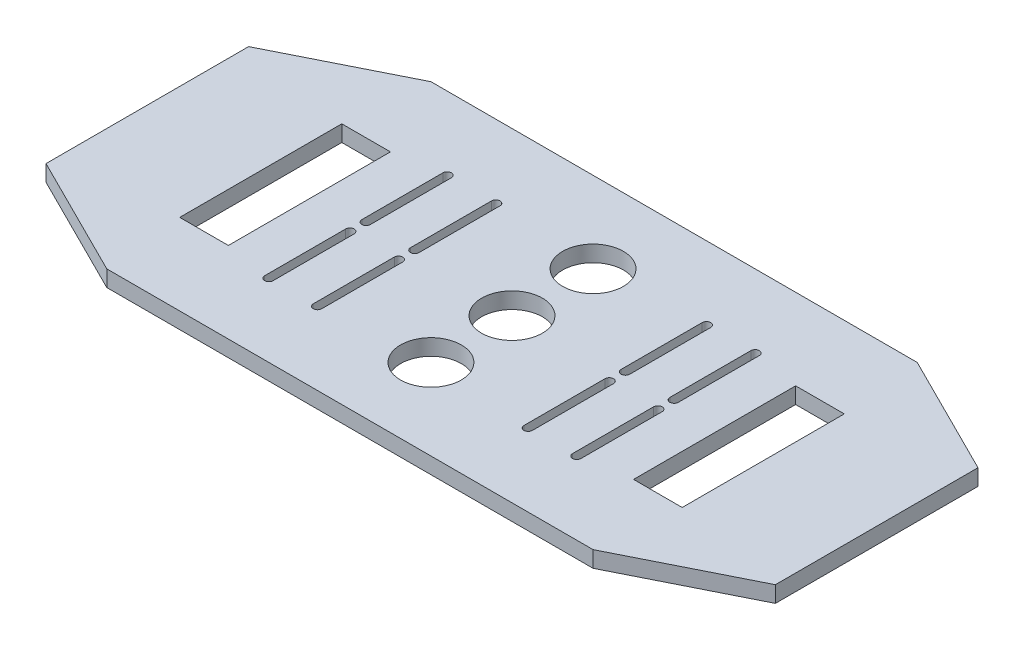
from build123d import *

# Parameters (mm, degrees)
ESQUISSE1_W                         = 180
ESQUISSE1_H                         = 80
BOSS_EXTRU_1_DEPTH                  = 4
ENL_V_MAT_EXTRU_1_DEPTH             = 4
ENL_V_MAT_EXTRU_2_DEPTH             = 4
ENL_V_MAT_EXTRU_5_REACH             = 6
ESQUISSE11_W                        = 12
ESQUISSE11_H                        = 40
ENL_V_MAT_EXTRU_5_DIRECTION_2_DEPTH = 1
ENL_V_MAT_EXTRU_6_REACH             = 6
ESQUISSE14_R                        = 7.5


with BuildPart() as part:
    # Esquisse1 → Boss.-Extru.1 (new body)
    with BuildSketch(Plane(origin=(0, 0, 0), x_dir=(1, 0, 0), z_dir=(0, 1, 0))):
        with Locations((90, 40)):
            Rectangle(ESQUISSE1_W, ESQUISSE1_H)
    extrude(amount=BOSS_EXTRU_1_DEPTH)

    # Esquisse2 → Enlèv. mat.-Extru.1 (cut)
    with BuildSketch(Plane(origin=(0, 4, 0), x_dir=(1, 0, 0), z_dir=(0, 1, 0))):
        Polygon((30, 0), (0, 15), (0, 0), align=None)
        Polygon((30, 80), (0, 65), (0, 80), align=None)
        Polygon((150, 0), (180, 15), (180, 0), align=None)
        Polygon((150, 80), (180, 80), (180, 65), align=None)
    extrude(amount=-ENL_V_MAT_EXTRU_1_DEPTH, mode=Mode.SUBTRACT)

    # Esquisse3 → Enlèv. mat.-Extru.2 (cut)
    with BuildSketch(Plane(origin=(0, 4, 0), x_dir=(1, 0, 0), z_dir=(0, 1, 0))):
        with BuildLine():
            Line((65.05, 38), (65.05, 18))
            ThreePointArc((65.05, 18), (64, 16.95), (62.95, 18))
            Line((62.95, 18), (62.95, 38))
            ThreePointArc((62.95, 38), (64, 39.05), (65.05, 38))
        make_face()
        with BuildLine():
            Line((50.95, 18), (50.95, 38))
            ThreePointArc((50.95, 38), (52, 39.05), (53.05, 38))
            Line((53.05, 38), (53.05, 18))
            ThreePointArc((53.05, 18), (52, 16.95), (50.95, 18))
        make_face()
        with BuildLine():
            Line((129.05, 18), (129.05, 38))
            ThreePointArc((129.05, 38), (128, 39.05), (126.95, 38))
            Line((126.95, 38), (126.95, 18))
            ThreePointArc((126.95, 18), (128, 16.95), (129.05, 18))
        make_face()
        with BuildLine():
            Line((114.95, 38), (114.95, 18))
            ThreePointArc((114.95, 18), (116, 16.95), (117.05, 18))
            Line((117.05, 18), (117.05, 38))
            ThreePointArc((117.05, 38), (116, 39.05), (114.95, 38))
        make_face()
        with BuildLine():
            Line((50.95, 62), (50.95, 42))
            ThreePointArc((50.95, 42), (52, 40.95), (53.05, 42))
            Line((53.05, 42), (53.05, 62))
            ThreePointArc((53.05, 62), (52, 63.05), (50.95, 62))
        make_face()
        with BuildLine():
            Line((65.05, 42), (65.05, 62))
            ThreePointArc((65.05, 62), (64, 63.05), (62.95, 62))
            Line((62.95, 62), (62.95, 42))
            ThreePointArc((62.95, 42), (64, 40.95), (65.05, 42))
        make_face()
        with BuildLine():
            Line((114.95, 42), (114.95, 62))
            ThreePointArc((114.95, 62), (116, 63.05), (117.05, 62))
            Line((117.05, 62), (117.05, 42))
            ThreePointArc((117.05, 42), (116, 40.95), (114.95, 42))
        make_face()
        with BuildLine():
            Line((129.05, 62), (129.05, 42))
            ThreePointArc((129.05, 42), (128, 40.95), (126.95, 42))
            Line((126.95, 42), (126.95, 62))
            ThreePointArc((126.95, 62), (128, 63.05), (129.05, 62))
        make_face()
    extrude(amount=-ENL_V_MAT_EXTRU_2_DEPTH, mode=Mode.SUBTRACT)

    # Esquisse11 → Enlèv. mat.-Extru.5 (cut, up to next)
    with BuildSketch(Plane(origin=(0, 4, 0), x_dir=(1, 0, 0), z_dir=(0, 1, 0)), mode=Mode.PRIVATE) as enl_v_mat_extru_5_sk1:
        with Locations((34, 40)):
            Rectangle(ESQUISSE11_W, ESQUISSE11_H)
    enl_v_mat_extru_5_tool1 = extrude(enl_v_mat_extru_5_sk1.sketch, amount=-ENL_V_MAT_EXTRU_5_REACH, mode=Mode.PRIVATE) & part.part
    add(enl_v_mat_extru_5_tool1.solids().sort_by_distance((34, 4, -40))[0], mode=Mode.SUBTRACT)
    # Esquisse11 → Enlèv. mat.-Extru.5 (cut, up to next)
    with BuildSketch(Plane(origin=(0, 4, 0), x_dir=(1, 0, 0), z_dir=(0, 1, 0)), mode=Mode.PRIVATE) as enl_v_mat_extru_5_sk2:
        with Locations((146, 40)):
            Rectangle(ESQUISSE11_W, ESQUISSE11_H)
    enl_v_mat_extru_5_tool2 = extrude(enl_v_mat_extru_5_sk2.sketch, amount=-ENL_V_MAT_EXTRU_5_REACH, mode=Mode.PRIVATE) & part.part
    add(enl_v_mat_extru_5_tool2.solids().sort_by_distance((146, 4, -40))[0], mode=Mode.SUBTRACT)

    # Esquisse11 → Enlèv. mat.-Extru.5 direction 2 (cut)
    with BuildSketch(Plane(origin=(0, 4, 0), x_dir=(1, 0, 0), z_dir=(0, 1, 0))):
        with Locations((34, 40)):
            Rectangle(ESQUISSE11_W, ESQUISSE11_H)
        with Locations((146, 40)):
            Rectangle(ESQUISSE11_W, ESQUISSE11_H)
    extrude(amount=ENL_V_MAT_EXTRU_5_DIRECTION_2_DEPTH, mode=Mode.SUBTRACT)

    # Esquisse14 → Enlèv. mat.-Extru.6 (cut, up to next)
    with BuildSketch(Plane(origin=(0, 4, 0), x_dir=(1, 0, 0), z_dir=(0, 1, 0)), mode=Mode.PRIVATE) as enl_v_mat_extru_6_sk1:
        with Locations((90, 60)):
            Circle(ESQUISSE14_R)
    enl_v_mat_extru_6_tool1 = extrude(enl_v_mat_extru_6_sk1.sketch, amount=-ENL_V_MAT_EXTRU_6_REACH, mode=Mode.PRIVATE) & part.part
    add(enl_v_mat_extru_6_tool1.solids().sort_by_distance((90, 4, -60))[0], mode=Mode.SUBTRACT)
    # Esquisse14 → Enlèv. mat.-Extru.6 (cut, up to next)
    with BuildSketch(Plane(origin=(0, 4, 0), x_dir=(1, 0, 0), z_dir=(0, 1, 0)), mode=Mode.PRIVATE) as enl_v_mat_extru_6_sk2:
        with Locations((90, 40)):
            Circle(ESQUISSE14_R)
    enl_v_mat_extru_6_tool2 = extrude(enl_v_mat_extru_6_sk2.sketch, amount=-ENL_V_MAT_EXTRU_6_REACH, mode=Mode.PRIVATE) & part.part
    add(enl_v_mat_extru_6_tool2.solids().sort_by_distance((90, 4, -40))[0], mode=Mode.SUBTRACT)
    # Esquisse14 → Enlèv. mat.-Extru.6 (cut, up to next)
    with BuildSketch(Plane(origin=(0, 4, 0), x_dir=(1, 0, 0), z_dir=(0, 1, 0)), mode=Mode.PRIVATE) as enl_v_mat_extru_6_sk3:
        with Locations((90, 20)):
            Circle(ESQUISSE14_R)
    enl_v_mat_extru_6_tool3 = extrude(enl_v_mat_extru_6_sk3.sketch, amount=-ENL_V_MAT_EXTRU_6_REACH, mode=Mode.PRIVATE) & part.part
    add(enl_v_mat_extru_6_tool3.solids().sort_by_distance((90, 4, -20))[0], mode=Mode.SUBTRACT)


solid = part.part
